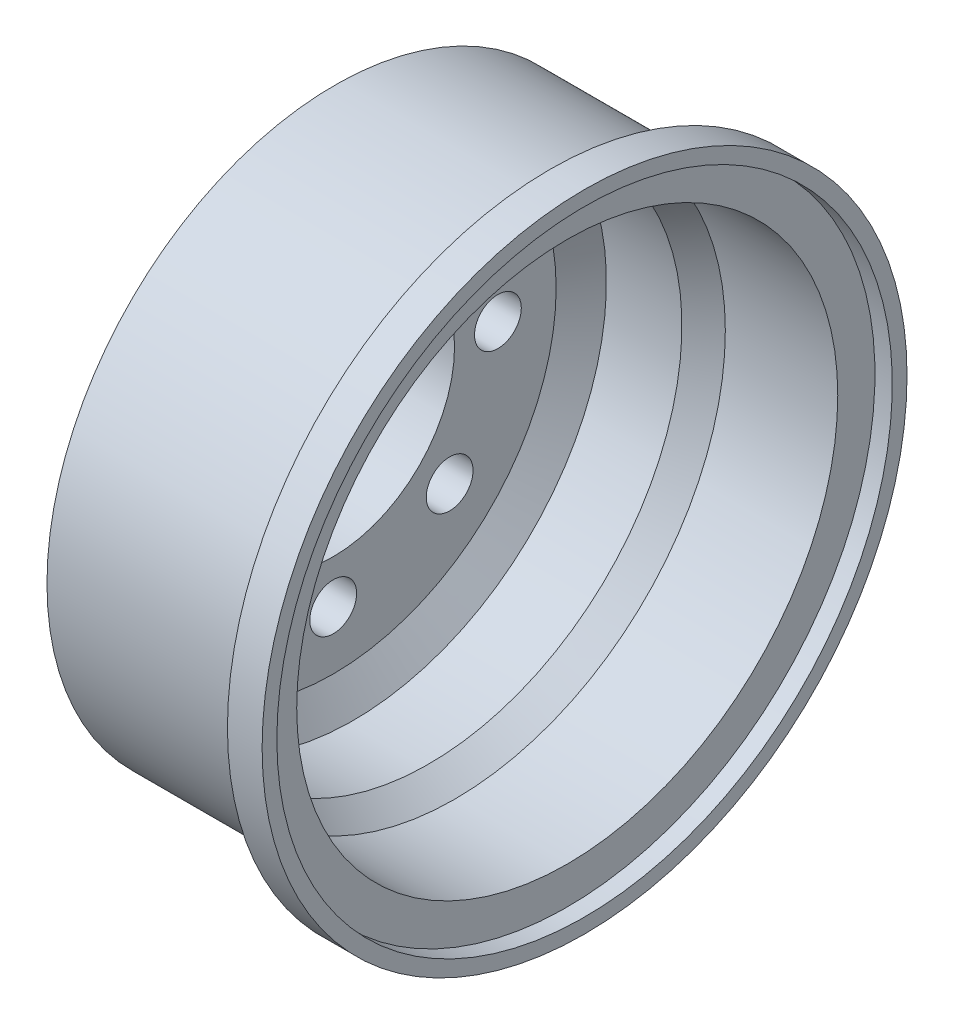
from build123d import *

# Parameters (mm, degrees)
SKETCH2_R          = 1.35
CUT_EXTRUDE1_DEPTH = 10


with BuildPart() as part:
    # Sketch1 → Revolve1 (revolve)
    with BuildSketch(Plane.XY):
        Polygon((-5.298096504, 7), (-5.298096504, 12.715801809), (-2.708631043, 16.6), (9.701368957, 16.6), (9.701368957, 18.6), (11.701368957, 18.6), (11.701368957, 17.75), (10.701368957, 17.75), (10.701368957, 15.604601484), (4.215618846, 15.604601484), (2.715618846, 14.6), (-1.638263526, 14.6), (-2.798096504, 12.860250534), (-2.798096504, 7), align=None)
    revolve(axis=Axis((-25, 0, 0), (1, 0, 0)))

    # Sketch2 → Cut-Extrude1 (cut)
    with BuildSketch(Plane(origin=(-2.798096504, 0, 0), x_dir=(0, 0, -1), z_dir=(1, 0, 0))):
        with Locations((0, 9.5)):
            Circle(SKETCH2_R)
        with Locations((6.717514421, 6.717514421)):
            Circle(SKETCH2_R)
        with Locations((9.5, 0)):
            Circle(SKETCH2_R)
        with Locations((6.717514421, -6.717514421)):
            Circle(SKETCH2_R)
        with Locations((0, -9.5)):
            Circle(SKETCH2_R)
        with Locations((-6.717514421, -6.717514421)):
            Circle(SKETCH2_R)
        with Locations((-9.5, 0)):
            Circle(SKETCH2_R)
        with Locations((-6.717514421, 6.717514421)):
            Circle(SKETCH2_R)
    extrude(amount=-CUT_EXTRUDE1_DEPTH, mode=Mode.SUBTRACT)


solid = part.part
